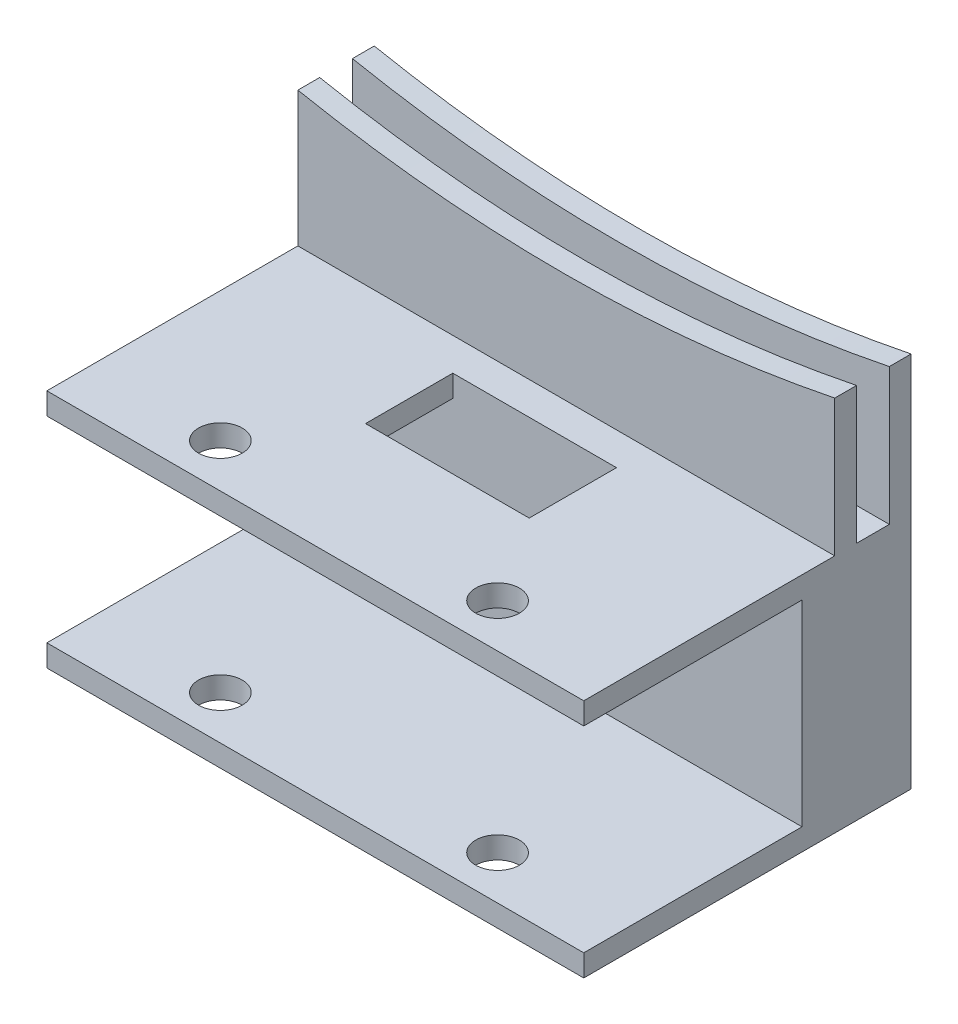
from build123d import *

# Parameters (mm, degrees)
SKETCH_1_W          = 49.2
SKETCH_1_H          = 30
EXTRUDE_1_DEPTH     = 22
SKETCH_2_W          = 49.2
SKETCH_2_H          = 2
EXTRUDE_2_DEPTH     = 20
CUT_EXTRUDE_1_DEPTH = 7
SKETCH_4_W          = 20
SKETCH_4_H          = 18
CUT_EXTRUDE_2_DEPTH = 50
SKETCH_5_R          = 2
CUT_EXTRUDE_3_DEPTH = 22
SKETCH_7_W          = 15
SKETCH_7_H          = 8
CUT_EXTRUDE_4_DEPTH = 2


with BuildPart() as part:
    # 스케치1 → 보스-돌출1 (new body)
    with BuildSketch(Plane(origin=(0, 0, 0), x_dir=(1, 0, 0), z_dir=(0, 1, 0))):
        with Locations((0.975657895, 5.148026316)):
            Rectangle(SKETCH_1_W, SKETCH_1_H)
    extrude(amount=EXTRUDE_1_DEPTH)

    # 스케치2 → 보스-돌출2 (add)
    with BuildSketch(Plane(origin=(0, 22, 0), x_dir=(1, 0, 0), z_dir=(0, 1, 0))):
        with Locations((0.975657895, 19.148026316)):
            Rectangle(SKETCH_2_W, SKETCH_2_H)
        with Locations((0.975657895, 14.148026316)):
            Rectangle(SKETCH_2_W, SKETCH_2_H)
    extrude(amount=EXTRUDE_2_DEPTH)

    # 스케치3 → 컷-돌출1 (cut)
    with BuildSketch(Plane(origin=(0, 0, -20.148026316), x_dir=(-1, 0, 0), z_dir=(0, 0, -1))):
        with BuildLine():
            Line((-25.575657895, 42), (23.624342105, 42))
            Line((23.624342105, 42), (23.624342105, 34.364931606))
            ThreePointArc((23.624342105, 34.364931606), (-0.983636552, 32.000665788), (-25.575657895, 34.525512861))
            Line((-25.575657895, 34.525512861), (-25.575657895, 42))
        make_face()
    extrude(amount=-CUT_EXTRUDE_1_DEPTH, mode=Mode.SUBTRACT)

    # 스케치4 → 컷-돌출2 (cut)
    with BuildSketch(Plane.ZY.offset(23.624342105)):
        with Locations((-0.148026316, 11)):
            Rectangle(SKETCH_4_W, SKETCH_4_H)
    extrude(amount=-CUT_EXTRUDE_2_DEPTH, mode=Mode.SUBTRACT)

    # 스케치5 → 컷-돌출3 (cut)
    with BuildSketch(Plane.XZ):
        with Locations((13.675657895, 5.851973684)):
            Circle(SKETCH_5_R)
        with Locations((-11.724342105, 5.851973684)):
            Circle(SKETCH_5_R)
    extrude(amount=-CUT_EXTRUDE_3_DEPTH, mode=Mode.SUBTRACT)

    # 스케치7 → 컷-돌출4 (cut)
    with BuildSketch(Plane(origin=(0, 22, 0), x_dir=(1, 0, 0), z_dir=(0, 1, 0))):
        with Locations((1.075657895, 6.148026316)):
            Rectangle(SKETCH_7_W, SKETCH_7_H)
    extrude(amount=-CUT_EXTRUDE_4_DEPTH, mode=Mode.SUBTRACT)


solid = part.part
